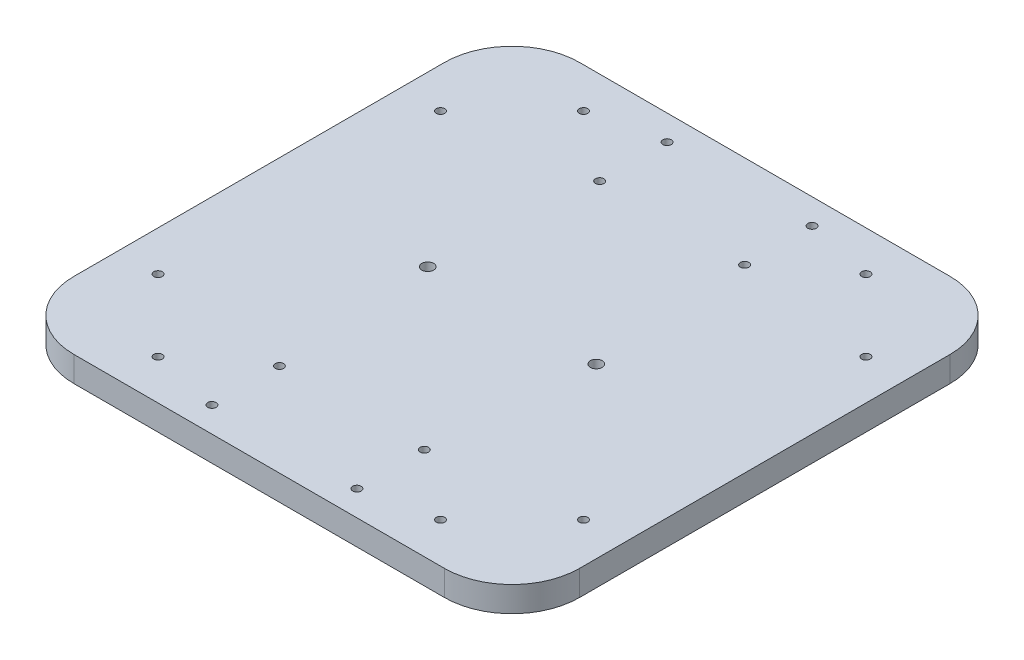
from build123d import *

# Parameters (mm, degrees)
SKETCH1_W               = 300
SKETCH1_H               = 15
BOSS_EXTRUDE1_DEPTH     = 150
SKETCH5_R               = 3.5
CUT_EXTRUDE3_DEPTH      = 1
CUT_EXTRUDE3_DEPTH_BACK = 16
SKETCH8_R               = 2.5
CUT_EXTRUDE5_DEPTH      = 16
FILLET4_R               = 40
SKETCH9_R               = 2.5
CUT_EXTRUDE6_DEPTH      = 16


with BuildPart() as part:
    # Sketch1 → Boss-Extrude1 (new body, symmetric)
    with BuildSketch(Plane.XY):
        Rectangle(SKETCH1_W, SKETCH1_H)
    extrude(amount=BOSS_EXTRUDE1_DEPTH, both=True)

    # Sketch5 → Cut-Extrude3 (cut, two sides)
    with BuildSketch(Plane.XZ.offset(7.5)) as cut_extrude3_sk:
        with Locations((50, 0)):
            Circle(SKETCH5_R)
        with Locations((-50, 0)):
            Circle(SKETCH5_R)
    extrude(amount=CUT_EXTRUDE3_DEPTH, mode=Mode.SUBTRACT)
    extrude(cut_extrude3_sk.sketch, amount=-CUT_EXTRUDE3_DEPTH_BACK, mode=Mode.SUBTRACT)

    # Sketch8 → Cut-Extrude5 (cut, through all)
    with BuildSketch(Plane.XZ.offset(7.5)):
        with Locations((-126.213203436, 83.786796564)):
            Circle(SKETCH8_R)
        with Locations((-83.786796564, 126.213203436)):
            Circle(SKETCH8_R)
        with Locations((126.213203436, 83.786796564)):
            Circle(SKETCH8_R)
        with Locations((83.786796564, 126.213203436)):
            Circle(SKETCH8_R)
        with Locations((83.786796564, -126.213203436)):
            Circle(SKETCH8_R)
        with Locations((126.213203436, -83.786796564)):
            Circle(SKETCH8_R)
        with Locations((-126.213203436, -83.786796564)):
            Circle(SKETCH8_R)
        with Locations((-83.786796564, -126.213203436)):
            Circle(SKETCH8_R)
    extrude(amount=-CUT_EXTRUDE5_DEPTH, mode=Mode.SUBTRACT)

    # Fillet4
    fillet4_edges = [part.edges().sort_by_distance(p)[0] for p in [
        (-150, 0, 150),
        (150, 0, 150),
        (-150, 0, -150),
        (150, 0, -150),
    ]]
    fillet(fillet4_edges, radius=FILLET4_R)

    # Sketch9 → Cut-Extrude6 (cut, through all)
    with BuildSketch(Plane(origin=(0, -7.5, 0), x_dir=(-1, 0, 0), z_dir=(0, -1, 0))):
        with Locations((43, -135)):
            Circle(SKETCH9_R)
        with Locations((-43, -135)):
            Circle(SKETCH9_R)
        with Locations((-43, -95)):
            Circle(SKETCH9_R)
        with Locations((43, -95)):
            Circle(SKETCH9_R)
        with Locations((-43, 95)):
            Circle(SKETCH9_R)
        with Locations((-43, 135)):
            Circle(SKETCH9_R)
        with Locations((43, 135)):
            Circle(SKETCH9_R)
        with Locations((43, 95)):
            Circle(SKETCH9_R)
    extrude(amount=-CUT_EXTRUDE6_DEPTH, mode=Mode.SUBTRACT)


solid = part.part
